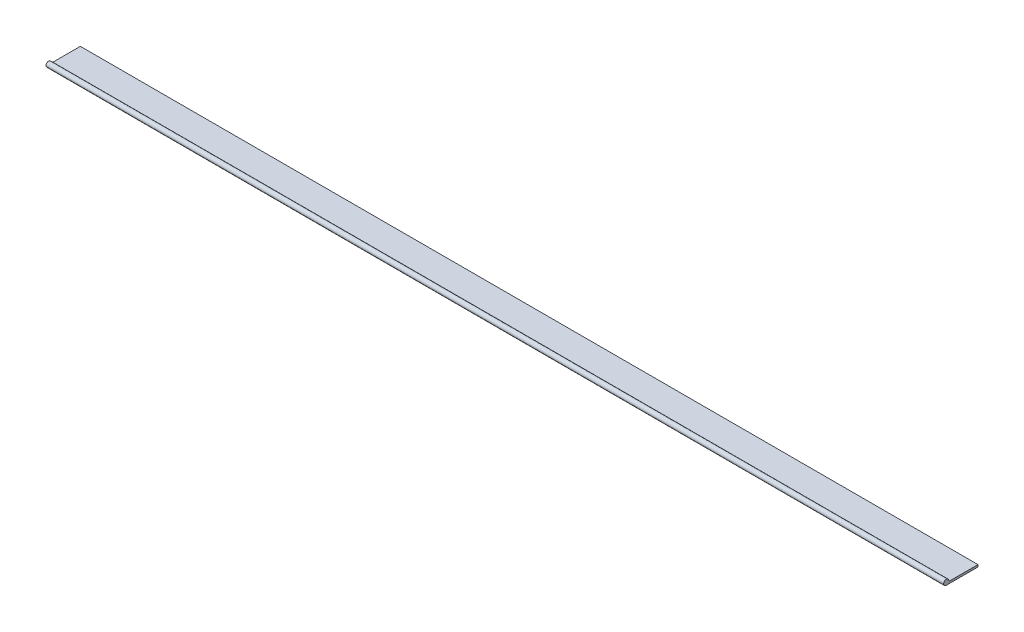
from build123d import *

# Parameters (mm, degrees)
BOSS_EXTRUDE1_DEPTH = 273.05


with BuildPart() as part:
    # Sketch1 → Boss-Extrude1 (new body)
    with BuildSketch(Plane(origin=(0, 0, 0), x_dir=(0, 0, -1), z_dir=(1, 0, 0))):
        with BuildLine():
            Line((0, 0), (9.652, 0))
            Line((9.652, 0), (9.652, 0.635))
            Line((9.652, 0.635), (0.777712993, 0.635))
            ThreePointArc((0.777712993, 0.635), (-0.502011579, 1.408586106), (0, 0))
        make_face()
    extrude(amount=BOSS_EXTRUDE1_DEPTH)


solid = part.part
